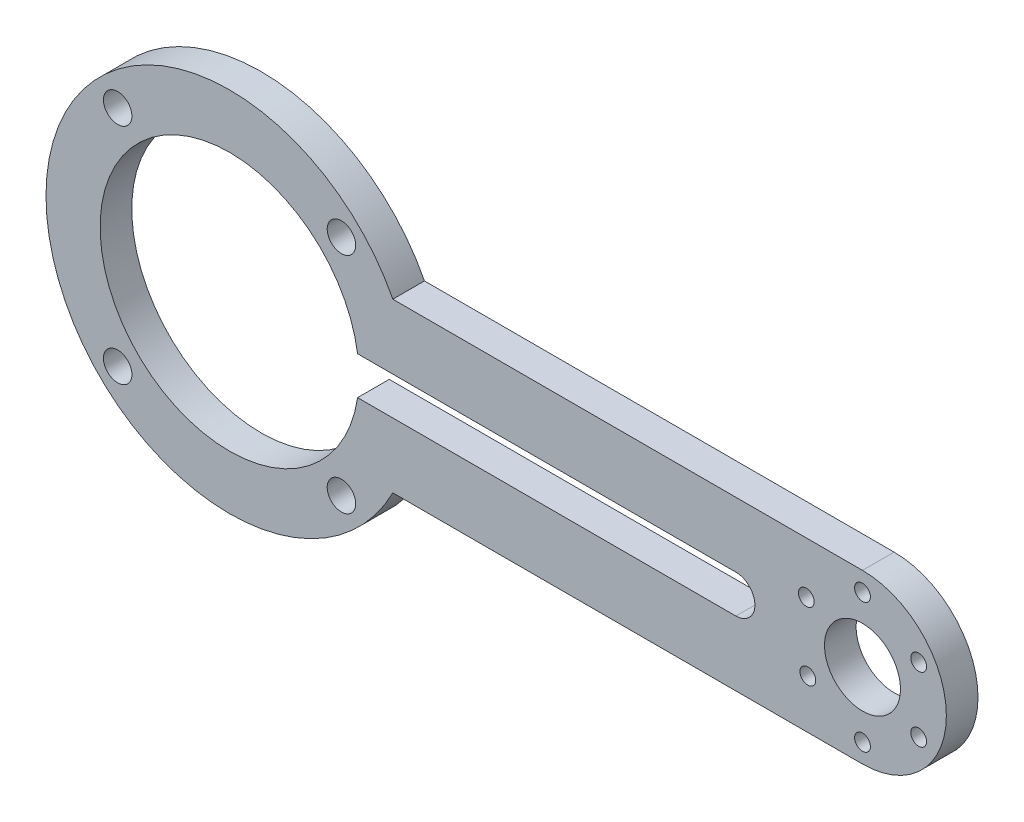
from build123d import *

# Parameters (mm, degrees)
SKETCH2_R           = 13.25
SKETCH2_R_2         = 6
BOSS_EXTRUDE1_DEPTH = 5
SKETCH3_R           = 2.25
SKETCH3_R_2         = 1.25
CUT_EXTRUDE1_DEPTH  = 6


with BuildPart() as part:
    # Sketch2 → Boss-Extrude1 (new body)
    with BuildSketch(Plane.XY):
        with BuildLine():
            ThreePointArc((15.576905983, -13.25), (-20.45, 0), (15.576905983, 13.25))
            Line((15.576905983, 13.25), (25.796075283, 13.25))
            ThreePointArc((25.796075283, 13.25), (-29, 0), (25.796075283, -13.25))
            Line((25.796075283, -13.25), (15.576905983, -13.25))
        make_face()
        with BuildLine():
            ThreePointArc((20.228754287, -3), (18.621948121, -8.451363686), (15.576905983, -13.25))
            Line((15.576905983, -13.25), (25.796075283, -13.25))
            ThreePointArc((25.796075283, -13.25), (27.796785579, -8.266723138), (28.844410204, -3))
            Line((28.844410204, -3), (20.228754287, -3))
        make_face()
        with BuildLine():
            Line((25.796075283, 13.25), (15.576905983, 13.25))
            ThreePointArc((15.576905983, 13.25), (18.621948121, 8.451363686), (20.228754287, 3))
            Line((20.228754287, 3), (28.844410204, 3))
            ThreePointArc((28.844410204, 3), (27.796785579, 8.266723138), (25.796075283, 13.25))
        make_face()
        with BuildLine():
            Line((100, 13.25), (25.796075283, 13.25))
            ThreePointArc((25.796075283, 13.25), (27.796785579, 8.266723138), (28.844410204, 3))
            Line((28.844410204, 3), (50, 3))
            Line((50, 3), (80, 3))
            ThreePointArc((80, 3), (82.121320344, 2.121320344), (83, 0))
            ThreePointArc((83, 0), (82.121320344, -2.121320344), (80, -3))
            Line((80, -3), (50, -3))
            Line((50, -3), (28.844410204, -3))
            ThreePointArc((28.844410204, -3), (27.796785579, -8.266723138), (25.796075283, -13.25))
            Line((25.796075283, -13.25), (100, -13.25))
            ThreePointArc((100, -13.25), (86.75, 0), (100, 13.25))
        make_face()
        with Locations((100, 0)):
            Circle(SKETCH2_R)
        with Locations((100, 0)):
            Circle(SKETCH2_R_2, mode=Mode.SUBTRACT)
    extrude(amount=BOSS_EXTRUDE1_DEPTH)

    # Sketch3 → Cut-Extrude1 (cut, through all)
    with BuildSketch(Plane.XY.offset(5)):
        with Locations((17.67766953, 17.67766953)):
            Circle(SKETCH3_R)
        with Locations((17.67766953, -17.67766953)):
            Circle(SKETCH3_R)
        with Locations((-17.67766953, -17.67766953)):
            Circle(SKETCH3_R)
        with Locations((-17.67766953, 17.67766953)):
            Circle(SKETCH3_R)
        with Locations((100, 10.25)):
            Circle(SKETCH3_R_2)
        with Locations((108.876760389, 5.125)):
            Circle(SKETCH3_R_2)
        with Locations((91.123239611, 5.125)):
            Circle(SKETCH3_R_2)
        with Locations((91.362305232, -5.518399142)):
            Circle(SKETCH3_R_2)
        with Locations((108.876760389, -5.125)):
            Circle(SKETCH3_R_2)
        with Locations((100, -10.25)):
            Circle(SKETCH3_R_2)
    extrude(amount=-CUT_EXTRUDE1_DEPTH, mode=Mode.SUBTRACT)


solid = part.part
